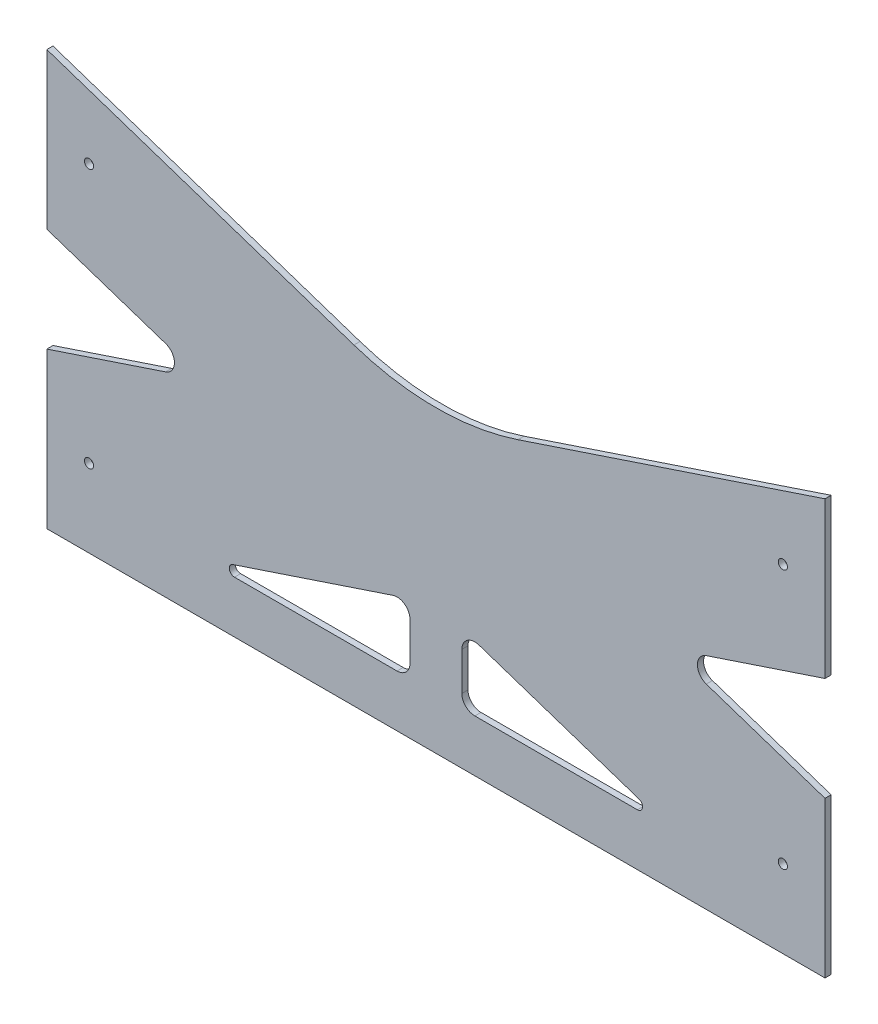
from build123d import *

# Parameters (mm, degrees)
BOSS_EXTRUDE1_DEPTH   = 3
SKETCH3_W             = 190.5
SKETCH3_H             = 25.4
BOSS_EXTRUDE2_DEPTH   = 3
BODY_MOVE_COPY1_ANGLE = 180
SKETCH5_W             = 25.4
SKETCH5_H             = 38.1
BOSS_EXTRUDE3_DEPTH   = 3
FILLET1_R             = 127
FILLET2_R             = 6.35
FILLET3_R             = 2.54
F_8_CLEARANCE_HOLE1_D = 4.4958


with BuildPart() as part:
    # Sketch1 → Boss-Extrude1 (new body)
    with BuildSketch(Plane.XY):
        Polygon((-381, 127), (0, 0), (0, 76.2), (-381, 203.2), align=None)
    extrude(amount=BOSS_EXTRUDE1_DEPTH)

    # Sketch3 → Boss-Extrude2 (add)
    with BuildSketch(Plane.XY.offset(3)):
        with Locations((-95.25, 12.7)):
            Rectangle(SKETCH3_W, SKETCH3_H)
    extrude(amount=-BOSS_EXTRUDE2_DEPTH)


with BuildPart() as body_2:
    # Body-Move_Copy1: copy of part
    add(part.part.rotate(Axis((-190.5, 0, 1.5), (0, 1, 0)), BODY_MOVE_COPY1_ANGLE))

    # Combine1: union part
    add(part.part)

    # Sketch5 → Boss-Extrude3 (add)
    with BuildSketch(Plane.XY.offset(3)):
        with Locations((-190.5, 44.45)):
            Rectangle(SKETCH5_W, SKETCH5_H)
    extrude(amount=-BOSS_EXTRUDE3_DEPTH)

    # Fillet1
    fillet1_edges = [body_2.edges().sort_by_distance(p)[0] for p in [
        (-190.5, 139.7, 1.5),
    ]]
    fillet(fillet1_edges, radius=FILLET1_R)

    # Fillet2
    fillet2_edges = [body_2.edges().sort_by_distance(p)[0] for p in [
        (-304.8, 101.6, 1.5),
        (-76.2, 101.6, 1.5),
        (-177.8, 59.266666667, 1.5),
        (-203.2, 25.4, 1.5),
        (-177.8, 25.4, 1.5),
        (-203.2, 59.266666667, 1.5),
    ]]
    fillet(fillet2_edges, radius=FILLET2_R)

    # Fillet3
    fillet3_edges = [body_2.edges().sort_by_distance(p)[0] for p in [
        (-304.8, 25.4, 1.5),
        (-76.2, 25.4, 1.5),
    ]]
    fillet(fillet3_edges, radius=FILLET3_R)

    # 8 Clearance Hole1 (through all)
    with Locations(Plane(origin=(0, 0, 0), x_dir=(-1, 0, 0), z_dir=(0, 0, -1))):
        with Locations((20.6375, 165.1), (360.3625, 165.1), (20.6375, 38.1), (360.3625, 38.1)):
            Hole(F_8_CLEARANCE_HOLE1_D / 2)


solid = body_2.part
